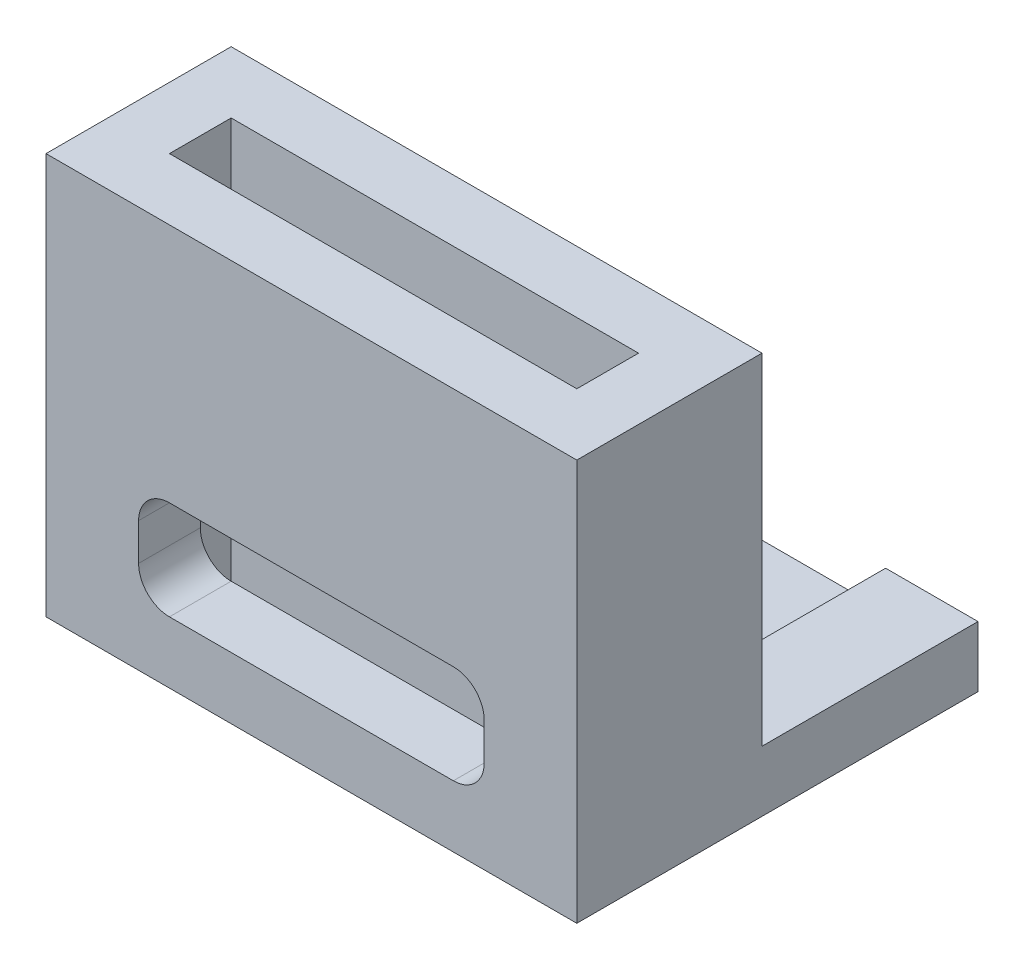
from build123d import *

# Parameters (mm, degrees)
SKETCH1_W           = 17.2
SKETCH1_H           = 6
SKETCH1_W_2         = 13.2
SKETCH1_H_2         = 2
BOSS_EXTRUDE1_DEPTH = 13
CUT_EXTRUDE1_DEPTH  = 13
SKETCH4_W           = 17.2
SKETCH4_H           = 1.968955047
BOSS_EXTRUDE2_DEPTH = 7
SKETCH5_R           = 1.6
CUT_EXTRUDE2_DEPTH  = 4
SKETCH6_W           = 11.206506984
SKETCH6_H           = 2.48590404
CUT_EXTRUDE3_DEPTH  = 7


with BuildPart() as part:
    # Sketch1 → Boss-Extrude1 (new body)
    with BuildSketch(Plane(origin=(0, 0, 0), x_dir=(1, 0, 0), z_dir=(0, 1, 0))):
        with Locations((6.6, 1)):
            Rectangle(SKETCH1_W, SKETCH1_H)
        with Locations((6.6, 1)):
            Rectangle(SKETCH1_W_2, SKETCH1_H_2, mode=Mode.SUBTRACT)
    extrude(amount=BOSS_EXTRUDE1_DEPTH)

    # Sketch2 → Cut-Extrude1 (cut)
    with BuildSketch(Plane.XY.offset(2)):
        with BuildLine():
            Line((2, 5.2), (11.2, 5.2))
            ThreePointArc((11.2, 5.2), (11.907106781, 4.907106781), (12.2, 4.2))
            Line((12.2, 4.2), (12.2, 3))
            ThreePointArc((12.2, 3), (11.907106781, 2.292893219), (11.2, 2))
            Line((11.2, 2), (2, 2))
            ThreePointArc((2, 2), (1.292893219, 2.292893219), (1, 3))
            Line((1, 3), (1, 4.2))
            ThreePointArc((1, 4.2), (1.292893219, 4.907106781), (2, 5.2))
        make_face()
    extrude(amount=-CUT_EXTRUDE1_DEPTH, mode=Mode.SUBTRACT)

    # Sketch4 → Boss-Extrude2 (add)
    with BuildSketch(Plane(origin=(0, 0, -4), x_dir=(-1, 0, 0), z_dir=(0, 0, -1))):
        with Locations((-6.6, 0.984477524)):
            Rectangle(SKETCH4_W, SKETCH4_H)
    extrude(amount=BOSS_EXTRUDE2_DEPTH)

    # Sketch5 → Cut-Extrude2 (cut)
    with BuildSketch(Plane(origin=(0, 1.968955047, 0), x_dir=(1, 0, 0), z_dir=(0, 1, 0))):
        with Locations((6.6, 7.5)):
            Circle(SKETCH5_R)
    extrude(amount=-CUT_EXTRUDE2_DEPTH, mode=Mode.SUBTRACT)

    # Sketch6 → Cut-Extrude3 (cut)
    with BuildSketch(Plane(origin=(0, 0, -11), x_dir=(-1, 0, 0), z_dir=(0, 0, -1))):
        with Locations((-6.603253492, 1.995400835)):
            Rectangle(SKETCH6_W, SKETCH6_H)
    extrude(amount=-CUT_EXTRUDE3_DEPTH, mode=Mode.SUBTRACT)


solid = part.part
